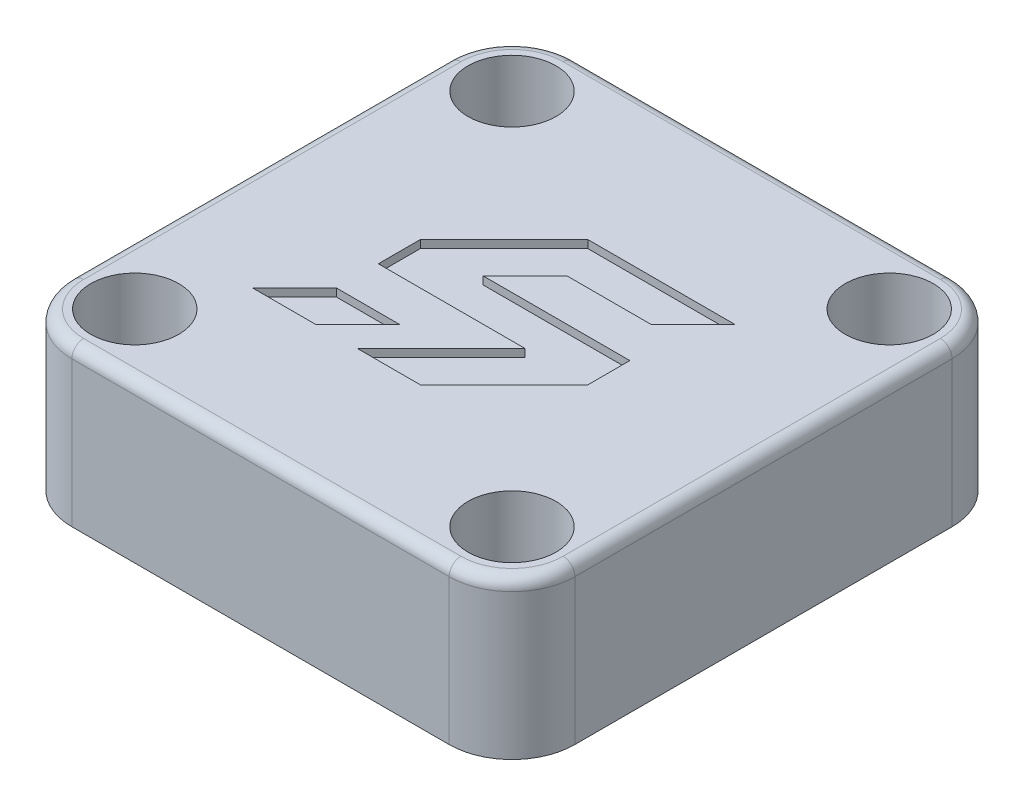
from build123d import *

# Parameters (mm, degrees)
SKETCH1_R           = 1.6
BOSS_EXTRUDE1_DEPTH = 10
CUT_EXTRUDE1_DEPTH  = 8.5
SKETCH3_R           = 2.8
CUT_EXTRUDE2_DEPTH  = 8
FILLET1_R           = 3
FILLET2_R           = 3
FILLET3_R           = 0.75
CUT_EXTRUDE3_DEPTH  = 0.5


with BuildPart() as part:
    # Sketch1 → Boss-Extrude1 (new body)
    with BuildSketch(Plane(origin=(0, 0, 0), x_dir=(1, 0, 0), z_dir=(0, 1, 0))):
        with BuildLine():
            ThreePointArc((12, -16), (14.828427125, -14.828427125), (16, -12))
            Line((16, -12), (16, 12))
            ThreePointArc((16, 12), (14.828427125, 14.828427125), (12, 16))
            Line((12, 16), (-12, 16))
            ThreePointArc((-12, 16), (-14.828427125, 14.828427125), (-16, 12))
            Line((-16, 12), (-16, -12))
            ThreePointArc((-16, -12), (-14.828427125, -14.828427125), (-12, -16))
            Line((-12, -16), (12, -16))
        make_face()
        with Locations((-12, -12)):
            Circle(SKETCH1_R, mode=Mode.SUBTRACT)
        with Locations((12, -12)):
            Circle(SKETCH1_R, mode=Mode.SUBTRACT)
        with Locations((-12, 12)):
            Circle(SKETCH1_R, mode=Mode.SUBTRACT)
        with Locations((12, 12)):
            Circle(SKETCH1_R, mode=Mode.SUBTRACT)
    extrude(amount=BOSS_EXTRUDE1_DEPTH)

    # Sketch2 → Cut-Extrude1 (cut)
    with BuildSketch(Plane.XZ):
        with BuildLine():
            Line((-8, -16), (8, -16))
            Line((8, -16), (8, -11.489125293))
            ThreePointArc((8, -11.489125293), (0, 14), (-8, -11.489125293))
            Line((-8, -11.489125293), (-8, -16))
        make_face()
    extrude(amount=-CUT_EXTRUDE1_DEPTH, mode=Mode.SUBTRACT)

    # Sketch3 → Cut-Extrude2 (cut)
    with BuildSketch(Plane(origin=(0, 10, 0), x_dir=(1, 0, 0), z_dir=(0, 1, 0))):
        with Locations((-12, 12)):
            Circle(SKETCH3_R)
        with Locations((12, 12)):
            Circle(SKETCH3_R)
        with Locations((12, -12)):
            Circle(SKETCH3_R)
        with Locations((-12, -12)):
            Circle(SKETCH3_R)
    extrude(amount=-CUT_EXTRUDE2_DEPTH, mode=Mode.SUBTRACT)

    # Fillet1
    fillet1_edges = [part.edges().sort_by_distance(p)[0] for p in [
        (8, 4.25, -11.489125293),
        (-8, 4.25, -11.489125293),
    ]]
    fillet(fillet1_edges, radius=FILLET1_R)

    # Fillet2
    fillet2_edges = [part.edges().sort_by_distance(p)[0] for p in [
        (8, 8.5, -14.480740698),
        (-8, 8.5, -14.480740698),
        (0, 8.5, 14),
        (-8.277544361, 8.5, -11.701229321),
        (8.277544361, 8.5, -11.701229321),
    ]]
    fillet(fillet2_edges, radius=FILLET2_R)

    # Fillet3
    fillet3_edges = [part.edges().sort_by_distance(p)[0] for p in [
        (0, 10, 16),
        (14.828427125, 10, 14.828427125),
        (16, 10, 0),
        (14.828427125, 10, -14.828427125),
        (0, 10, -16),
        (-14.828427125, 10, -14.828427125),
        (-16, 10, 0),
        (-14.828427125, 10, 14.828427125),
    ]]
    fillet(fillet3_edges, radius=FILLET3_R)

    # Sketch6 → Cut-Extrude3 (cut)
    with BuildSketch(Plane(origin=(0, 10, 0), x_dir=(1, 0, 0), z_dir=(0, 1, 0))):
        Polygon((-6.741615885, -7.094845439), (-4.074949219, -4.428178772), (-6.741615885, -4.428178772), (-9.408282552, -7.094845439), align=None)
        Polygon((-2.741615885, -4.428178772), (-4.074949219, -4.428178772), (-6.741615885, -7.094845439), (-5.408282552, -7.094845439), align=None)
        Polygon((1.258384115, -7.094845439), (3.925050781, -4.428178772), (-0.074949219, -4.428178772), (-2.741615885, -7.094845439), align=None)
        Polygon((3.925050781, -4.428178772), (6.591717448, -1.761512106), (2.591717448, -1.761512106), (-0.074949219, -4.428178772), align=None)
        Polygon((6.591717448, 0.905154561), (5.258384115, 0.905154561), (2.591717448, -1.761512106), (6.591717448, -1.761512106), align=None)
        Polygon((2.591717448, -1.761512106), (5.258384115, 0.905154561), (1.258384115, 0.905154561), (-1.408282552, -1.761512106), align=None)
        Polygon((-1.408282552, -1.761512106), (1.258384115, 0.905154561), (-2.741615885, 0.905154561), (-5.408282552, -1.761512106), align=None)
        Polygon((-5.408282552, -1.761512106), (-2.741615885, 0.905154561), (-6.741615885, 0.905154561), (-6.741615885, -1.761512106), align=None)
        Polygon((-2.741615885, 0.905154561), (-0.074949219, 3.571821228), (-4.074949219, 3.571821228), (-6.741615885, 0.905154561), align=None)
        Polygon((-0.074949219, 3.571821228), (2.591717448, 6.238487894), (-1.408282552, 6.238487894), (-4.074949219, 3.571821228), align=None)
        Polygon((3.925050781, 3.571821228), (6.591717448, 6.238487894), (2.591717448, 6.238487894), (-0.074949219, 3.571821228), align=None)
        Polygon((5.258384115, 3.571821228), (7.925050781, 6.238487894), (6.591717448, 6.238487894), (3.925050781, 3.571821228), align=None)
    extrude(amount=-CUT_EXTRUDE3_DEPTH, mode=Mode.SUBTRACT)


solid = part.part
